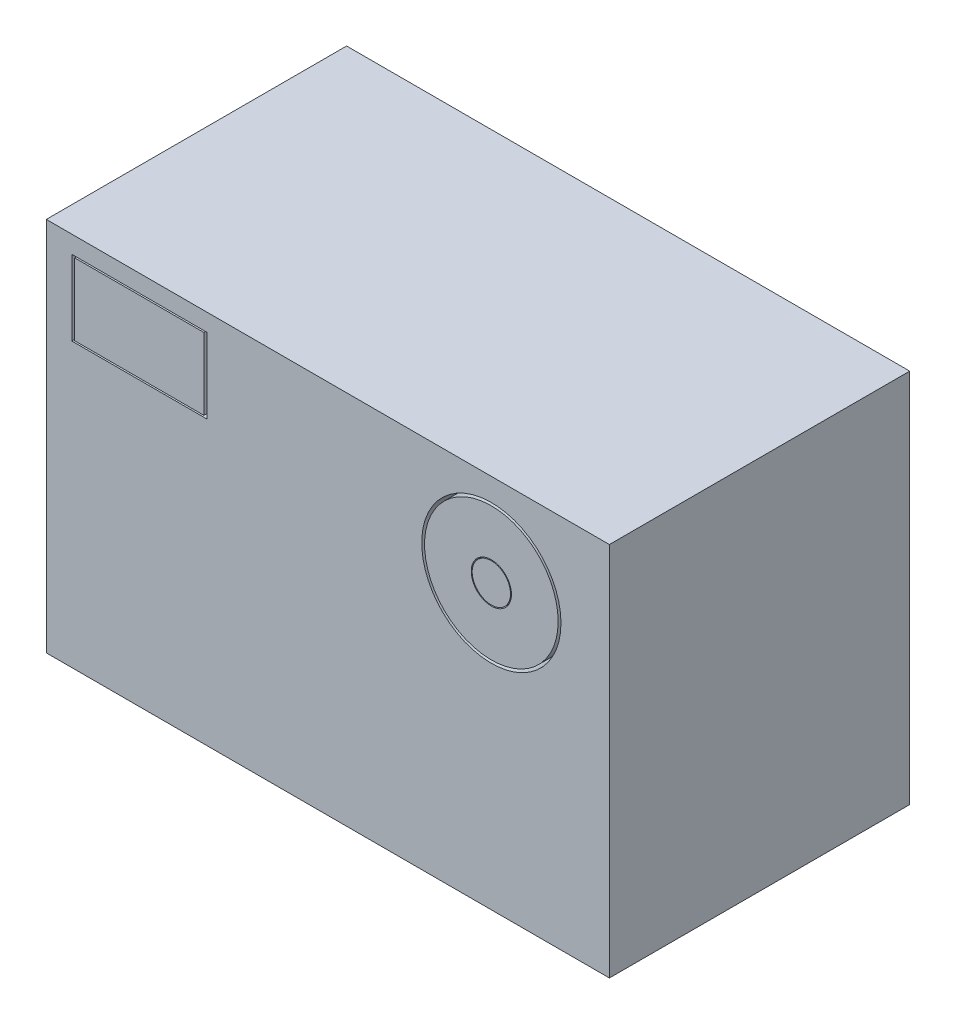
from build123d import *

# Parameters (mm, degrees)
SKETCH1_W           = 75
SKETCH1_H           = 50
BOSS_EXTRUDE1_DEPTH = 40
SKETCH2_R           = 9.272983733
CUT_EXTRUDE1_DEPTH  = 14
SKETCH3_R           = 8.895673095
SKETCH3_R_2         = 2.676649409
BOSS_EXTRUDE2_DEPTH = 14
SKETCH4_R           = 2.552861956
BOSS_EXTRUDE3_DEPTH = 14
SKETCH5_W           = 18
SKETCH5_H           = 10
SKETCH5_W_2         = 17.211665491
SKETCH5_H_2         = 9.562036384
CUT_EXTRUDE2_DEPTH  = 7
SKETCH6_R           = 5
CUT_EXTRUDE3_DEPTH  = 10


with BuildPart() as part:
    # Sketch1 → Boss-Extrude1 (new body)
    with BuildSketch(Plane.XY):
        Rectangle(SKETCH1_W, SKETCH1_H)
    extrude(amount=BOSS_EXTRUDE1_DEPTH)

    # Sketch2 → Cut-Extrude1 (cut)
    with BuildSketch(Plane.XY.offset(40)):
        with Locations((21.778192922, 12.714084695)):
            Circle(SKETCH2_R)
    extrude(amount=-CUT_EXTRUDE1_DEPTH, mode=Mode.SUBTRACT)

    # Sketch3 → Boss-Extrude2 (add)
    with BuildSketch(Plane.XY.offset(26)):
        with Locations((21.778192922, 12.714084695)):
            Circle(SKETCH3_R)
        with Locations((21.778192922, 12.714084695)):
            Circle(SKETCH3_R_2, mode=Mode.SUBTRACT)
    extrude(amount=BOSS_EXTRUDE2_DEPTH)

    # Sketch4 → Boss-Extrude3 (add)
    with BuildSketch(Plane.XY.offset(26)):
        with Locations((21.778192922, 12.714084695)):
            Circle(SKETCH4_R)
    extrude(amount=BOSS_EXTRUDE3_DEPTH)

    # Sketch5 → Cut-Extrude2 (cut)
    with BuildSketch(Plane.XY.offset(40)):
        with Locations((-25.106926905, 17.674362133)):
            Rectangle(SKETCH5_W, SKETCH5_H)
        with Locations((-25.106926904, 17.674362133)):
            Rectangle(SKETCH5_W_2, SKETCH5_H_2, mode=Mode.SUBTRACT)
    extrude(amount=-CUT_EXTRUDE2_DEPTH, mode=Mode.SUBTRACT)

    # Sketch6 → Cut-Extrude3 (cut)
    with BuildSketch(Plane.XZ.offset(25)):
        with Locations((0, 20)):
            Circle(SKETCH6_R)
    extrude(amount=-CUT_EXTRUDE3_DEPTH, mode=Mode.SUBTRACT)


solid = part.part
